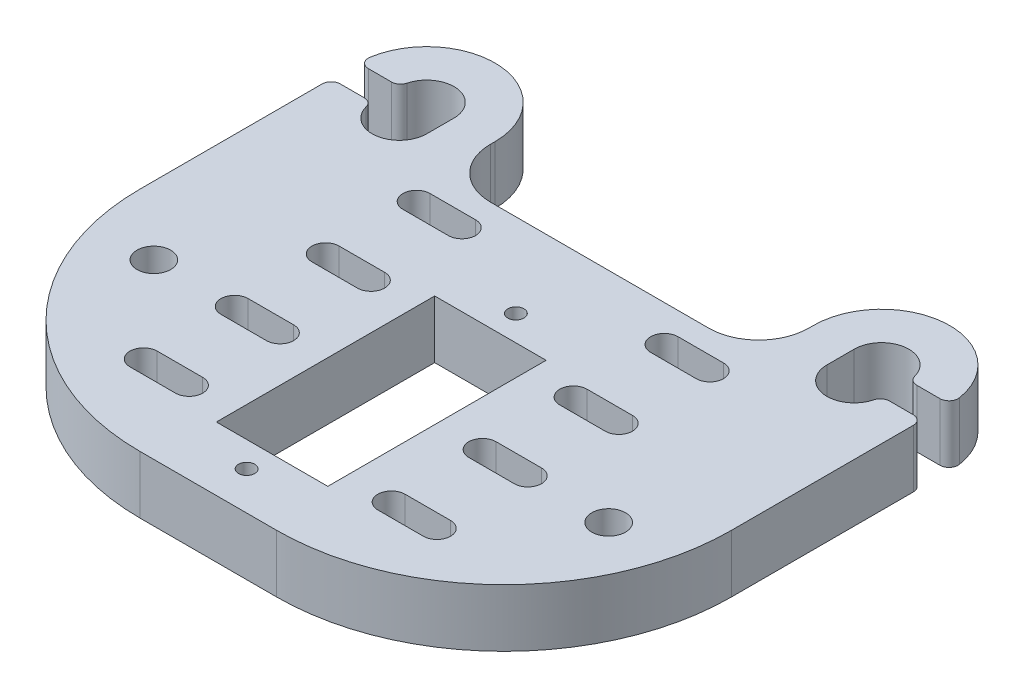
from build123d import *

# Parameters (mm, degrees)
SKETCH1_R           = 0.889
SKETCH1_R_2         = 1.85293
SKETCH1_W           = 12.25
SKETCH1_H           = 24
BOSS_EXTRUDE1_DEPTH = 6.35


with BuildPart() as part:
    # Sketch1 → Boss-Extrude1 (new body)
    with BuildSketch(Plane(origin=(0, 0, 0), x_dir=(1, 0, 0), z_dir=(0, 1, 0))):
        with BuildLine():
            Line((-25.79604899, 10.914446368), (-25.79604899, 28.914446368))
            Line((-25.79604899, 28.914446368), (-25.79604899, 30.914446368))
            ThreePointArc((-25.79604899, 30.914446368), (-25.503155771, 31.621553149), (-24.79604899, 31.914446368))
            Line((-24.79604899, 31.914446368), (-22.169032336, 31.914446368))
            ThreePointArc((-22.169032336, 31.914446368), (-21.5566599, 31.705015783), (-21.200786499, 31.164446368))
            ThreePointArc((-21.200786499, 31.164446368), (-17.918036112, 28.938357279), (-15.29604899, 31.914446368))
            Line((-15.29604899, 31.914446368), (-15.29604899, 34.914446368))
            ThreePointArc((-15.29604899, 34.914446368), (-17.918036112, 37.890535457), (-21.200786499, 35.664446368))
            ThreePointArc((-21.200786499, 35.664446368), (-21.5566599, 35.123876953), (-22.169032336, 34.914446368))
            Line((-22.169032336, 34.914446368), (-24.718665279, 34.914446368))
            ThreePointArc((-24.718665279, 34.914446368), (-25.478219804, 35.264002732), (-25.706760093, 36.068292522))
            ThreePointArc((-25.706760093, 36.068292522), (-17.717401115, 42.392090826), (-10.79604899, 34.914446368))
            Line((-10.79604899, 34.914446368), (-10.79604899, 34.414446368))
            ThreePointArc((-10.79604899, 34.414446368), (-9.185136286, 30.525359071), (-5.29604899, 28.914446368))
            Line((-5.29604899, 28.914446368), (18.70395101, 28.914446368))
            ThreePointArc((18.70395101, 28.914446368), (22.593038307, 30.525359071), (24.20395101, 34.414446368))
            Line((24.20395101, 34.414446368), (24.20395101, 34.914446368))
            ThreePointArc((24.20395101, 34.914446368), (31.125303135, 42.392090826), (39.114662113, 36.068292522))
            ThreePointArc((39.114662113, 36.068292522), (38.886121825, 35.264002732), (38.126567299, 34.914446368))
            Line((38.126567299, 34.914446368), (35.576934356, 34.914446368))
            ThreePointArc((35.576934356, 34.914446368), (34.964561921, 35.123876953), (34.60868852, 35.664446368))
            ThreePointArc((34.60868852, 35.664446368), (31.325938133, 37.890535457), (28.70395101, 34.914446368))
            Line((28.70395101, 34.914446368), (28.70395101, 31.914446368))
            ThreePointArc((28.70395101, 31.914446368), (31.325938133, 28.938357279), (34.60868852, 31.164446368))
            ThreePointArc((34.60868852, 31.164446368), (34.964561921, 31.705015783), (35.576934356, 31.914446368))
            Line((35.576934356, 31.914446368), (38.20395101, 31.914446368))
            ThreePointArc((38.20395101, 31.914446368), (38.911057791, 31.621553149), (39.20395101, 30.914446368))
            Line((39.20395101, 30.914446368), (39.20395101, 28.914446368))
            Line((39.20395101, 28.914446368), (39.20395101, 10.914446368))
            ThreePointArc((39.20395101, 10.914446368), (31.88162054, -6.763223162), (14.20395101, -14.085553632))
            Line((14.20395101, -14.085553632), (-0.79604899, -14.085553632))
            ThreePointArc((-0.79604899, -14.085553632), (-18.47371852, -6.763223162), (-25.79604899, 10.914446368))
        make_face()
        with Locations((6.70395101, 19.714446368)):
            Circle(SKETCH1_R, mode=Mode.SUBTRACT)
        with Locations((6.70395101, -9.885553632)):
            Circle(SKETCH1_R, mode=Mode.SUBTRACT)
        with Locations((-18.29604899, 4.914446368)):
            Circle(SKETCH1_R_2, mode=Mode.SUBTRACT)
        with Locations((31.70395101, 4.914446368)):
            Circle(SKETCH1_R_2, mode=Mode.SUBTRACT)
        with Locations((6.70395101, 4.914446368)):
            Rectangle(SKETCH1_W, SKETCH1_H, mode=Mode.SUBTRACT)
        with BuildLine():
            Line((-9.42104899, 6.414446368), (-4.42104899, 6.414446368))
            ThreePointArc((-4.42104899, 6.414446368), (-2.92104899, 4.914446368), (-4.42104899, 3.414446368))
            Line((-4.42104899, 3.414446368), (-9.42104899, 3.414446368))
            ThreePointArc((-9.42104899, 3.414446368), (-10.92104899, 4.914446368), (-9.42104899, 6.414446368))
        make_face(mode=Mode.SUBTRACT)
        with BuildLine():
            Line((22.82895101, 3.414446368), (17.82895101, 3.414446368))
            ThreePointArc((17.82895101, 3.414446368), (16.32895101, 4.914446368), (17.82895101, 6.414446368))
            Line((17.82895101, 6.414446368), (22.82895101, 6.414446368))
            ThreePointArc((22.82895101, 6.414446368), (24.32895101, 4.914446368), (22.82895101, 3.414446368))
        make_face(mode=Mode.SUBTRACT)
        with BuildLine():
            Line((-9.42104899, -3.585553632), (-4.42104899, -3.585553632))
            ThreePointArc((-4.42104899, -3.585553632), (-2.92104899, -5.085553632), (-4.42104899, -6.585553632))
            Line((-4.42104899, -6.585553632), (-9.42104899, -6.585553632))
            ThreePointArc((-9.42104899, -6.585553632), (-10.92104899, -5.085553632), (-9.42104899, -3.585553632))
        make_face(mode=Mode.SUBTRACT)
        with BuildLine():
            Line((22.82895101, -6.585553632), (17.82895101, -6.585553632))
            ThreePointArc((17.82895101, -6.585553632), (16.32895101, -5.085553632), (17.82895101, -3.585553632))
            Line((17.82895101, -3.585553632), (22.82895101, -3.585553632))
            ThreePointArc((22.82895101, -3.585553632), (24.32895101, -5.085553632), (22.82895101, -6.585553632))
        make_face(mode=Mode.SUBTRACT)
        with BuildLine():
            Line((-9.42104899, 16.414446368), (-4.42104899, 16.414446368))
            ThreePointArc((-4.42104899, 16.414446368), (-2.92104899, 14.914446368), (-4.42104899, 13.414446368))
            Line((-4.42104899, 13.414446368), (-9.42104899, 13.414446368))
            ThreePointArc((-9.42104899, 13.414446368), (-10.92104899, 14.914446368), (-9.42104899, 16.414446368))
        make_face(mode=Mode.SUBTRACT)
        with BuildLine():
            Line((22.82895101, 13.414446368), (17.82895101, 13.414446368))
            ThreePointArc((17.82895101, 13.414446368), (16.32895101, 14.914446368), (17.82895101, 16.414446368))
            Line((17.82895101, 16.414446368), (22.82895101, 16.414446368))
            ThreePointArc((22.82895101, 16.414446368), (24.32895101, 14.914446368), (22.82895101, 13.414446368))
        make_face(mode=Mode.SUBTRACT)
        with BuildLine():
            Line((-9.42104899, 26.414446368), (-4.42104899, 26.414446368))
            ThreePointArc((-4.42104899, 26.414446368), (-2.92104899, 24.914446368), (-4.42104899, 23.414446368))
            Line((-4.42104899, 23.414446368), (-9.42104899, 23.414446368))
            ThreePointArc((-9.42104899, 23.414446368), (-10.92104899, 24.914446368), (-9.42104899, 26.414446368))
        make_face(mode=Mode.SUBTRACT)
        with BuildLine():
            Line((22.82895101, 23.414446368), (17.82895101, 23.414446368))
            ThreePointArc((17.82895101, 23.414446368), (16.32895101, 24.914446368), (17.82895101, 26.414446368))
            Line((17.82895101, 26.414446368), (22.82895101, 26.414446368))
            ThreePointArc((22.82895101, 26.414446368), (24.32895101, 24.914446368), (22.82895101, 23.414446368))
        make_face(mode=Mode.SUBTRACT)
    extrude(amount=BOSS_EXTRUDE1_DEPTH)


solid = part.part
